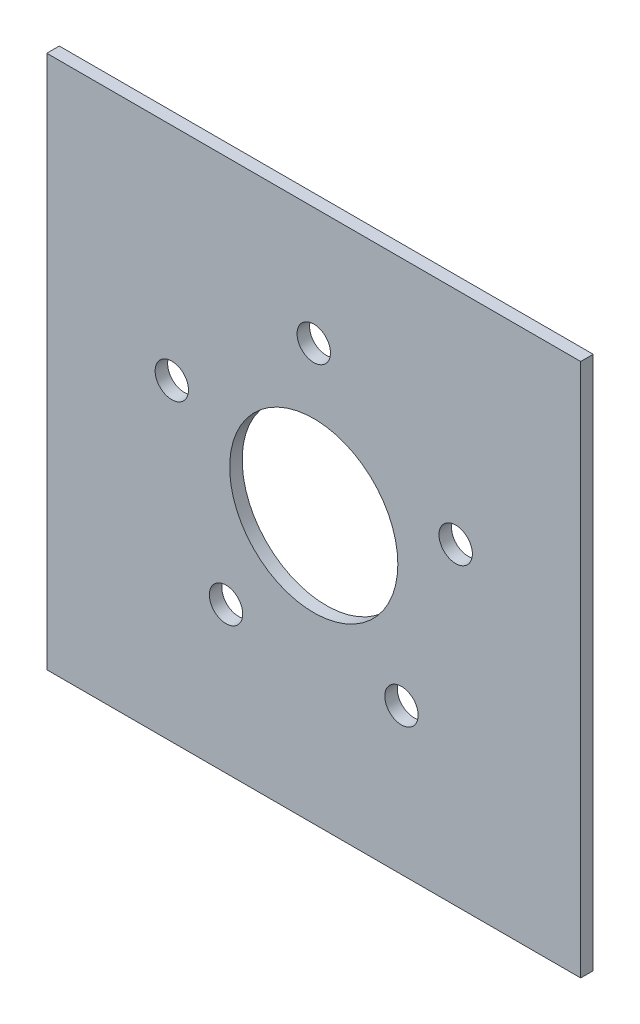
from build123d import *

# Parameters (mm, degrees)
SKETCH4_W           = 203.2
SKETCH4_H           = 203.2
SKETCH4_R           = 6.35
SKETCH4_R_2         = 32.004
BOSS_EXTRUDE1_DEPTH = 4.7625


with BuildPart() as part:
    # Sketch4 → Boss-Extrude1 (new body)
    with BuildSketch(Plane.XY):
        Rectangle(SKETCH4_W, SKETCH4_H)
        with Locations((-54.018973032, 17.551828308)):
            Circle(SKETCH4_R, mode=Mode.SUBTRACT)
        with Locations((0, 56.798909535)):
            Circle(SKETCH4_R, mode=Mode.SUBTRACT)
        with Locations((-33.385561371, -45.951283076)):
            Circle(SKETCH4_R, mode=Mode.SUBTRACT)
        with Locations((33.385561371, -45.951283076)):
            Circle(SKETCH4_R, mode=Mode.SUBTRACT)
        with Locations((54.018973032, 17.551828308)):
            Circle(SKETCH4_R, mode=Mode.SUBTRACT)
        Circle(SKETCH4_R_2, mode=Mode.SUBTRACT)
    extrude(amount=BOSS_EXTRUDE1_DEPTH)


solid = part.part
